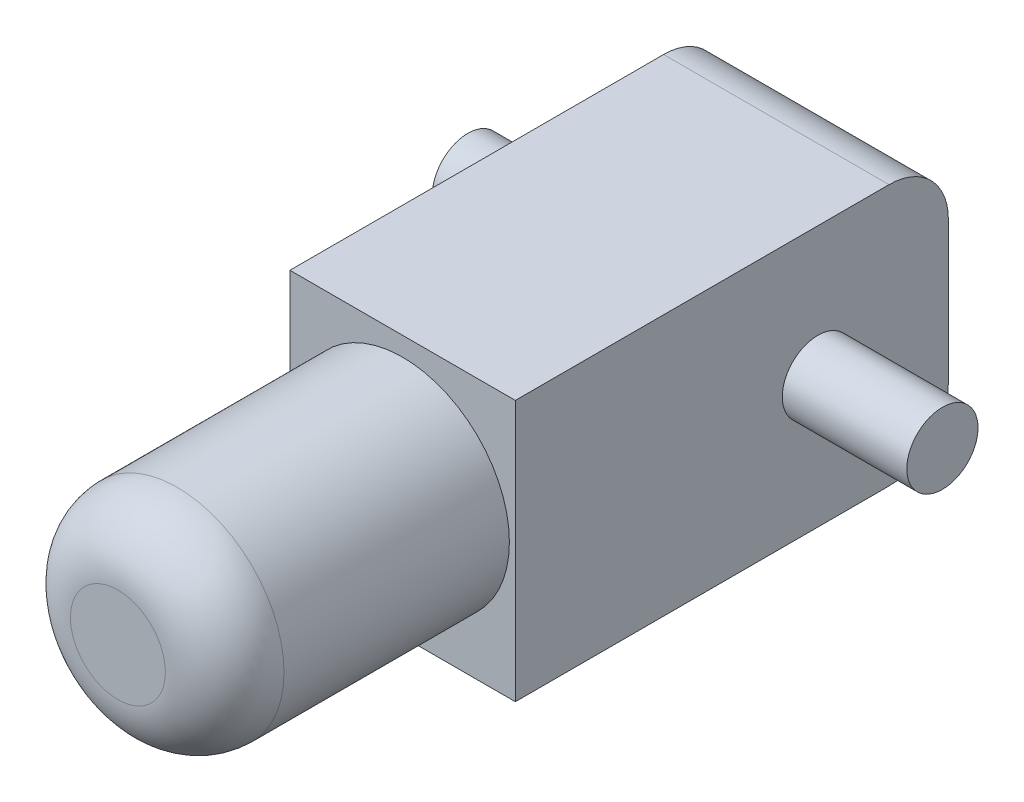
from build123d import *

# Parameters (mm, degrees)
SKETCH_1_W      = 36.5
SKETCH_1_H      = 22
EXTRUDE_1_DEPTH = 19
SKETCH_3_R      = 3
EXTRUDE_3_DEPTH = 20
FILLET_1_R      = 5
SKETCH_4_R      = 9
EXTRUDE_4_DEPTH = 24
FILLET_2_R      = 5


with BuildPart() as part:
    # 草图1 → 凸台-拉伸1 (new body)
    with BuildSketch(Plane(origin=(0, 0, 0), x_dir=(0, 0, -1), z_dir=(1, 0, 0))):
        with Locations((18.25, 11)):
            Rectangle(SKETCH_1_W, SKETCH_1_H)
    extrude(amount=EXTRUDE_1_DEPTH)

    # 草图3 → 凸台-拉伸3 (add, symmetric)
    with BuildSketch(Plane(origin=(9.5, 0, 0), x_dir=(0, 0, -1), z_dir=(1, 0, 0))):
        with Locations((25.5, 11)):
            Circle(SKETCH_3_R)
    extrude(amount=EXTRUDE_3_DEPTH, both=True)

    # 圆角1
    fillet_1_edges = [part.edges().sort_by_distance(p)[0] for p in [
        (9.5, 22, -36.5),
        (9.5, 0, -36.5),
    ]]
    fillet(fillet_1_edges, radius=FILLET_1_R)

    # 草图4 → 凸台-拉伸4 (add)
    with BuildSketch(Plane.XY):
        with Locations((9.5, 11.405533056)):
            Circle(SKETCH_4_R)
    extrude(amount=EXTRUDE_4_DEPTH)

    # 圆角2
    fillet_2_edges = [part.edges().sort_by_distance(p)[0] for p in [
        (0.5, 11.405533056, 24),
    ]]
    fillet(fillet_2_edges, radius=FILLET_2_R)


solid = part.part
